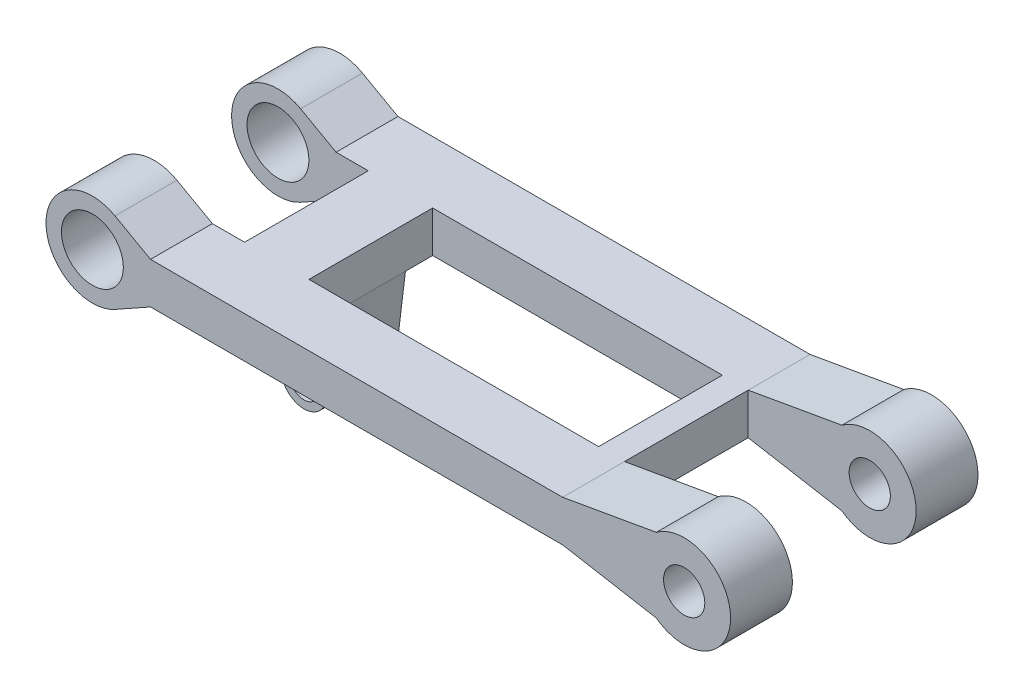
from build123d import *

# Parameters (mm, degrees)
SKETCH1_R           = 10
SKETCH1_R_2         = 15
BOSS_EXTRUDE1_DEPTH = 120
CUT_EXTRUDE1_DEPTH  = 45
SKETCH3_R           = 11
SKETCH3_R_2         = 7.2
BOSS_EXTRUDE2_DEPTH = 120
CUT_EXTRUDE2_DEPTH  = 180
SKETCH5_W           = 31.21991305
SKETCH5_H           = 33.6
BOSS_EXTRUDE3_DEPTH = 20
SKETCH6_W           = 31.21991305
SKETCH6_H           = 20
BOSS_EXTRUDE4_DEPTH = 13.2
SKETCH8_W           = 31.21991305
SKETCH8_H           = 20
BOSS_EXTRUDE5_DEPTH = 13.2
CUT_EXTRUDE3_DEPTH  = 40


with BuildPart() as part:
    # Sketch1 → Boss-Extrude1 (new body)
    with BuildSketch(Plane.XY):
        with BuildLine():
            Line((75, 10), (-124.86381146, 10))
            Line((-124.86381146, 10), (-142.062836025, 19.631407747))
            ThreePointArc((-142.062836025, 19.631407747), (-175.556371847, 0), (-142.062836025, -19.631407747))
            Line((-142.062836025, -19.631407747), (-124.86381146, -10))
            Line((-124.86381146, -10), (75, -10))
            Line((75, -10), (120.453543604, -18.000740708))
            ThreePointArc((120.453543604, -18.000740708), (156.452555937, 0), (120.453543604, 18.000740708))
            Line((120.453543604, 18.000740708), (75, 10))
        make_face()
        with Locations((133.952555937, 0)):
            Circle(SKETCH1_R, mode=Mode.SUBTRACT)
        with Locations((-153.056371847, 0)):
            Circle(SKETCH1_R_2, mode=Mode.SUBTRACT)
    extrude(amount=BOSS_EXTRUDE1_DEPTH)

    # Sketch2 → Cut-Extrude1 (cut, symmetric)
    with BuildSketch(Plane(origin=(0, 10, 0), x_dir=(1, 0, 0), z_dir=(0, 1, 0))):
        Polygon((-124.86381146, -90), (-124.86381146, -60), (-124.86381146, -30), (-189.632147982, -30), (-189.632147982, -90), align=None)
        Polygon((-124.86381146, -30), (-124.86381146, -60), (-124.86381146, -90), (62.44239577, -90), (62.44239577, -30), align=None)
    extrude(amount=CUT_EXTRUDE1_DEPTH, both=True, mode=Mode.SUBTRACT)

    # Sketch3 → Boss-Extrude2 (add)
    with BuildSketch(Plane.XY.offset(120)):
        with BuildLine():
            Line((-109.253854935, -10), (-104.64389841, -47.8166351))
            ThreePointArc((-104.64389841, -47.8166351), (-93.64389841, -36.8166351), (-82.64389841, -47.8166351))
            Line((-82.64389841, -47.8166351), (-78.033941885, -10))
            Line((-78.033941885, -10), (-109.253854935, -10))
        make_face()
        with Locations((-93.64389841, -47.8166351)):
            Circle(SKETCH3_R)
        with Locations((-93.64389841, -47.8166351)):
            Circle(SKETCH3_R_2, mode=Mode.SUBTRACT)
    extrude(amount=-BOSS_EXTRUDE2_DEPTH)

    # Sketch4 → Cut-Extrude2 (cut)
    with BuildSketch(Plane.ZY.offset(-62.44239577)):
        Polygon((43.2, -58.8166351), (43.2, -10), (30, -10), (-9.185341586, -10), (-9.185341586, -58.8166351), align=None)
        Polygon((90, -10), (76.8, -10), (76.8, -58.8166351), (133.966164795, -58.8166351), (133.966164795, -10), align=None)
    extrude(amount=CUT_EXTRUDE2_DEPTH, mode=Mode.SUBTRACT)

    # Sketch5 → Boss-Extrude3 (add)
    with BuildSketch(Plane(origin=(0, -10, 0), x_dir=(1, 0, 0), z_dir=(0, 1, 0))):
        with Locations((-93.64389841, -60)):
            Rectangle(SKETCH5_W, SKETCH5_H)
    extrude(amount=BOSS_EXTRUDE3_DEPTH)

    # Sketch6 → Boss-Extrude4 (add)
    with BuildSketch(Plane(origin=(0, 0, 43.2), x_dir=(-1, 0, 0), z_dir=(0, 0, -1))):
        with Locations((93.64389841, 0)):
            Rectangle(SKETCH6_W, SKETCH6_H)
    extrude(amount=BOSS_EXTRUDE4_DEPTH)

    # Sketch8 → Boss-Extrude5 (add)
    with BuildSketch(Plane(origin=(0, 0, 90), x_dir=(-1, 0, 0), z_dir=(0, 0, -1))):
        with Locations((93.64389841, 0)):
            Rectangle(SKETCH8_W, SKETCH8_H)
    extrude(amount=BOSS_EXTRUDE5_DEPTH)

    # Sketch9 → Cut-Extrude3 (cut, symmetric)
    with BuildSketch(Plane(origin=(0, 10, 0), x_dir=(1, 0, 0), z_dir=(0, 1, 0))):
        Polygon((156.452555937, -30), (156.452555937, -60), (156.452555937, -90), (75, -90), (75, -30), align=None)
    extrude(amount=CUT_EXTRUDE3_DEPTH, both=True, mode=Mode.SUBTRACT)


solid = part.part
